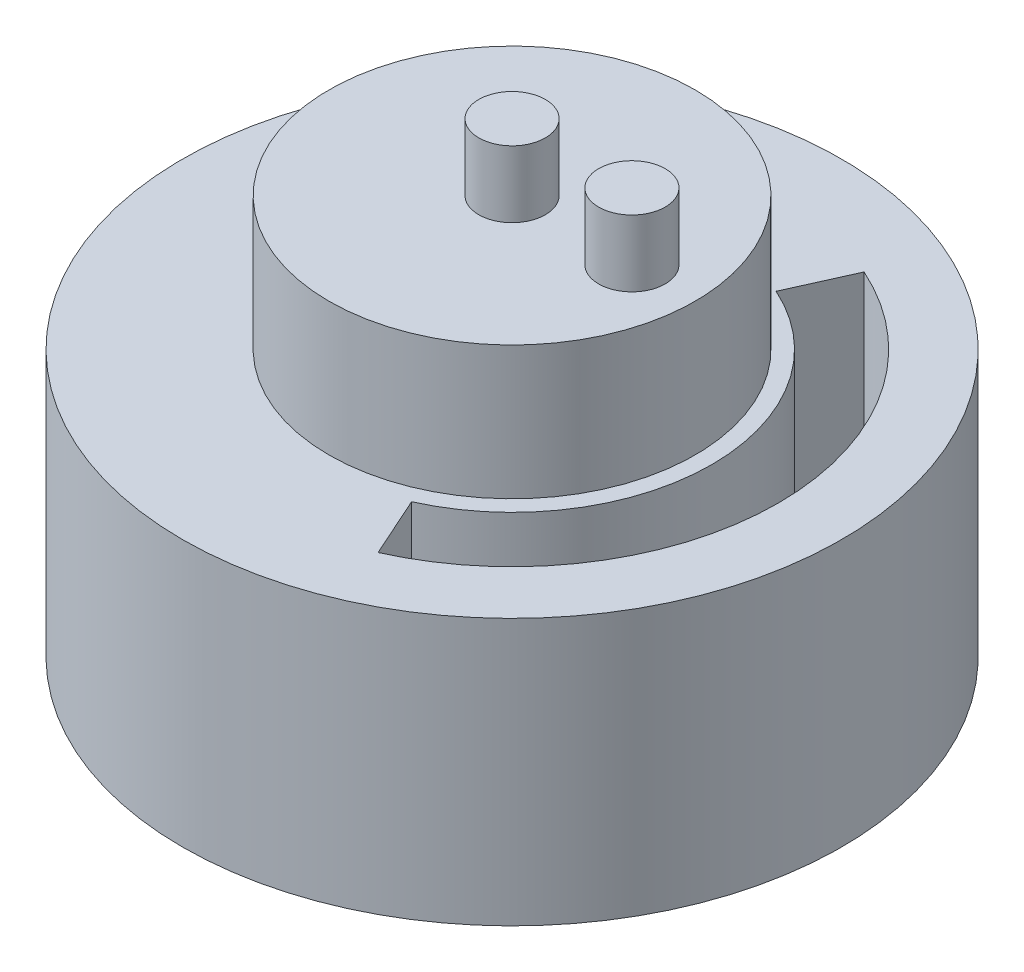
from build123d import *

# Parameters (mm, degrees)
RESSALTO_EXTRUS_O2_DEPTH = 20
ESBO_O3_R                = 13.75
BOSS_EXTRUDE1_DEPTH      = 10
SKETCH2_R                = 2.5
BOSS_EXTRUDE2_DEPTH      = 5
CUT_EXTRUDE2_DEPTH       = 20


with BuildPart() as part:
    # Esboço1 → Ressalto-extrusão2 (new body)
    with BuildSketch(Plane(origin=(0, 0, 0), x_dir=(1, 0, 0), z_dir=(0, 1, 0))):
        with BuildLine():
            ThreePointArc((-12.375, -21.434128744), (0, -24.75), (12.375, -21.434128744))
            ThreePointArc((12.375, -21.434128744), (21.434128744, -12.375), (24.75, 0))
            ThreePointArc((24.75, 0), (-12.375, 21.434128744), (-12.375, -21.434128744))
        make_face()
    extrude(amount=RESSALTO_EXTRUS_O2_DEPTH)

    # Esboço3 → Boss-Extrude1 (add)
    with BuildSketch(Plane(origin=(0, 20, 0), x_dir=(1, 0, 0), z_dir=(0, 1, 0))):
        Circle(ESBO_O3_R)
    extrude(amount=BOSS_EXTRUDE1_DEPTH)

    # Sketch2 → Boss-Extrude2 (add)
    with BuildSketch(Plane(origin=(0, 30, 0), x_dir=(1, 0, 0), z_dir=(0, 1, 0))):
        Circle(SKETCH2_R)
        with Locations((9, 0)):
            Circle(SKETCH2_R)
    extrude(amount=BOSS_EXTRUDE2_DEPTH)

    # Sketch3 → Cut-Extrude2 (cut)
    with BuildSketch(Plane(origin=(0, 20, 0), x_dir=(1, 0, 0), z_dir=(0, 1, 0))):
        with BuildLine():
            Line((8.185723081, -18.248121483), (6.13929231, -13.686091112))
            ThreePointArc((6.13929231, -13.686091112), (15, 0), (6.13929231, 13.686091112))
            Line((6.13929231, 13.686091112), (8.185723081, 18.248121483))
            ThreePointArc((8.185723081, 18.248121483), (20, 0), (8.185723081, -18.248121483))
        make_face()
    extrude(amount=-CUT_EXTRUDE2_DEPTH, mode=Mode.SUBTRACT)


solid = part.part
